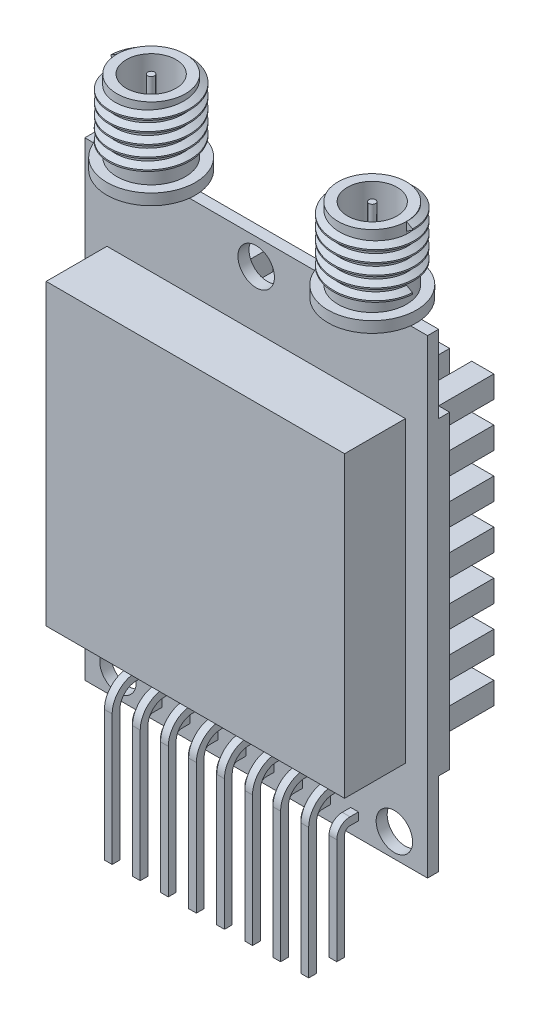
from build123d import *

# Parameters (mm, degrees)
SKETCH_1_W             = 31
SKETCH_1_H             = 42.5
EXTRUDE_1_DEPTH        = 1
SKETCH_2_W             = 27
SKETCH_2_H             = 27
EXTRUDE_2_DEPTH        = 5.5
SKETCH_3_R             = 4
EXTRUDE_3_DEPTH        = 1
SKETCH_4_R             = 3.1
EXTRUDE_4_DEPTH        = 6.5
SKETCH_6_R             = 2.25
CUT_EXTRUDE_1_DEPTH    = 5
SKETCH_7_R             = 0.3
EXTRUDE_5_DEPTH        = 5
THREAD_1_PITCH         = 1
THREAD_1_HEIGHT        = 5
THREAD_1_RADIUS        = 3.1
THREAD_1_START_ANGLE   = -90
EXTRUDE_START          = -6.25
EXTRUDE_6_DEPTH        = 0.7
EXTRUDE_6_2_DEPTH      = 0.7
PATTERN_LINEAR_1_COUNT = 8
PATTERN_LINEAR_1_PITCH = 2.54
SKETCH_9_R             = 1.65
CUT_EXTRUDE_2_DEPTH    = 60.086800641
SKETCH_10_W            = 31
SKETCH_10_H            = 28
EXTRUDE_7_DEPTH        = 6
SKETCH_11_W            = 5
SKETCH_11_H            = 2
CUT_EXTRUDE_3_DEPTH    = 60.188259055
CUT_EXTRUDE_4_REACH    = 53.415
SKETCH_12_W            = 2
SKETCH_12_H            = 5


with BuildPart() as part:
    # Эскиз1 → Бобышка-Вытянуть1 (new body)
    with BuildSketch(Plane.XY):
        with Locations((15.5, 21.25)):
            Rectangle(SKETCH_1_W, SKETCH_1_H)
    extrude(amount=EXTRUDE_1_DEPTH)

    # Sketch 2 → Бобышка-Вытянуть2 (add)
    with BuildSketch(Plane.XY.offset(1)):
        with Locations((15.5, 21.5)):
            Rectangle(SKETCH_2_W, SKETCH_2_H)
    extrude(amount=EXTRUDE_2_DEPTH)

    # Эскиз3 → Бобышка-Вытянуть3 (add)
    with BuildSketch(Plane(origin=(0, 42.5, 0), x_dir=(1, 0, 0), z_dir=(0, 1, 0))):
        with Locations(Location((5.5, -0.5, 0), (0, 0, 7.180755781))):
            Circle(SKETCH_3_R)
    extrude_3 = extrude(amount=EXTRUDE_3_DEPTH)

    # Эскиз4 → Бобышка-Вытянуть4 (add)
    with BuildSketch(Plane(origin=(0, 43.5, 0), x_dir=(1, 0, 0), z_dir=(0, 1, 0))):
        with Locations(Location((5.5, -0.5, 0), (0, 0, 90))):
            Circle(SKETCH_4_R)
    extrude_4 = extrude(amount=EXTRUDE_4_DEPTH)

    # Эскиз6 → Вырез-Вытянуть1 (cut)
    with BuildSketch(Plane(origin=(0, 50, 0), x_dir=(1, 0, 0), z_dir=(0, 1, 0))):
        with Locations(Location((5.5, -0.5, 0), (0, 0, 270))):
            Circle(SKETCH_6_R)
    cut_extrude_1 = extrude(amount=-CUT_EXTRUDE_1_DEPTH, mode=Mode.SUBTRACT)

    # Эскиз7 → Бобышка-Вытянуть5 (add)
    with BuildSketch(Plane(origin=(0, 45, 0), x_dir=(1, 0, 0), z_dir=(0, 1, 0))):
        with Locations(Location((5.5, -0.5, 0), (0, 0, 270))):
            Circle(SKETCH_7_R)
    extrude_5 = extrude(amount=EXTRUDE_5_DEPTH)

    # Резьба1: sweep along a helix
    with BuildLine() as thread_1_path:
        add(Helix(THREAD_1_PITCH, THREAD_1_HEIGHT, THREAD_1_RADIUS, center=(5.5, 50, 0.5), direction=(0, -1, 0), mode=Mode.PRIVATE).rotate(Axis((5.5, 50, 0.5), (0, -1, 0)), THREAD_1_START_ANGLE))
    # Sketch 2 2 → Резьба1 (sweep)
    with BuildSketch(Plane(origin=(2.4, 50, 0.5), x_dir=(-1, 0, 0), z_dir=(0, 0, 1))):
        Polygon((0, 0), (0.541265875, 0.312499999), (0.541265875, 0.437499999), (0, 0.749999997), align=None)
    thread_1 = sweep(path=thread_1_path.line, is_frenet=True)

    # Зеркальное отражение1: Бобышка-Вытянуть3, Бобышка-Вытянуть4, Вырез-Вытянуть1, Бобышка-Вытянуть5, Резьба1 across plane
    add(extrude_3.mirror(Plane(origin=(15.5, 0, 0), x_dir=(0, 0, 1), z_dir=(1, 0, 0))))
    add(extrude_4.mirror(Plane(origin=(15.5, 0, 0), x_dir=(0, 0, 1), z_dir=(1, 0, 0))))
    add(cut_extrude_1.mirror(Plane(origin=(15.5, 0, 0), x_dir=(0, 0, 1), z_dir=(1, 0, 0))), mode=Mode.SUBTRACT)
    add(extrude_5.mirror(Plane(origin=(15.5, 0, 0), x_dir=(0, 0, 1), z_dir=(1, 0, 0))))
    add(thread_1.mirror(Plane(origin=(15.5, 0, 0), x_dir=(0, 0, 1), z_dir=(1, 0, 0))))

    # Эскиз9 → Вырез-Вытянуть2 (cut, through all)
    with BuildSketch(Plane.XY.offset(1)):
        with Locations((15.5, 40.15)):
            Circle(SKETCH_9_R)
        with Locations((28, 2.15)):
            Circle(SKETCH_9_R)
        with Locations((3, 2.15)):
            Circle(SKETCH_9_R)
    extrude(amount=-CUT_EXTRUDE_2_DEPTH, mode=Mode.SUBTRACT)

    # Эскиз10 → Бобышка-Вытянуть7 (add)
    with BuildSketch(Plane(origin=(0, 0, 0), x_dir=(-1, 0, 0), z_dir=(0, 0, -1))):
        with Locations((-15.5, 21.5)):
            Rectangle(SKETCH_10_W, SKETCH_10_H)
    extrude(amount=EXTRUDE_7_DEPTH)

    # Эскиз11 → Вырез-Вытянуть3 (cut, through all)
    with BuildSketch(Plane.ZY):
        with Locations((-3.5, 32.5)):
            Rectangle(SKETCH_11_W, SKETCH_11_H)
        with Locations((-3.5, 28.5)):
            Rectangle(SKETCH_11_W, SKETCH_11_H)
        with Locations((-3.5, 24.5)):
            Rectangle(SKETCH_11_W, SKETCH_11_H)
        with Locations((-3.5, 20.5)):
            Rectangle(SKETCH_11_W, SKETCH_11_H)
        with Locations((-3.5, 16.5)):
            Rectangle(SKETCH_11_W, SKETCH_11_H)
        with Locations((-3.5, 12.5)):
            Rectangle(SKETCH_11_W, SKETCH_11_H)
        with Locations((-3.5, 8.5)):
            Rectangle(SKETCH_11_W, SKETCH_11_H)
    extrude(amount=-CUT_EXTRUDE_3_DEPTH, mode=Mode.SUBTRACT)

    # Вырез-Вытянуть4: up to this face of the body (flat: up to its plane)
    cut_extrude_4_end = Plane(part.part.faces().sort_by_distance((15.5, 35.5, -3))[0])
    # Эскиз12 → Вырез-Вытянуть4 (cut, up to the picked face)
    with BuildSketch(Plane.XZ.offset(-9.5), mode=Mode.PRIVATE) as cut_extrude_4_sk1:
        with Locations((3, -3.5)):
            Rectangle(SKETCH_12_W, SKETCH_12_H)
    cut_extrude_4_tool1 = split(extrude(cut_extrude_4_sk1.sketch, amount=-CUT_EXTRUDE_4_REACH, mode=Mode.PRIVATE), bisect_by=cut_extrude_4_end, keep=Keep.BOTH, mode=Mode.PRIVATE)
    # Эскиз12 → Вырез-Вытянуть4 (cut, up to the picked face)
    with BuildSketch(Plane.XZ.offset(-9.5), mode=Mode.PRIVATE) as cut_extrude_4_sk2:
        with Locations((7, -3.5)):
            Rectangle(SKETCH_12_W, SKETCH_12_H)
    cut_extrude_4_tool2 = split(extrude(cut_extrude_4_sk2.sketch, amount=-CUT_EXTRUDE_4_REACH, mode=Mode.PRIVATE), bisect_by=cut_extrude_4_end, keep=Keep.BOTH, mode=Mode.PRIVATE)
    # Эскиз12 → Вырез-Вытянуть4 (cut, up to the picked face)
    with BuildSketch(Plane.XZ.offset(-9.5), mode=Mode.PRIVATE) as cut_extrude_4_sk3:
        with Locations((11, -3.5)):
            Rectangle(SKETCH_12_W, SKETCH_12_H)
    cut_extrude_4_tool3 = split(extrude(cut_extrude_4_sk3.sketch, amount=-CUT_EXTRUDE_4_REACH, mode=Mode.PRIVATE), bisect_by=cut_extrude_4_end, keep=Keep.BOTH, mode=Mode.PRIVATE)
    # Эскиз12 → Вырез-Вытянуть4 (cut, up to the picked face)
    with BuildSketch(Plane.XZ.offset(-9.5), mode=Mode.PRIVATE) as cut_extrude_4_sk4:
        with Locations((15, -3.5)):
            Rectangle(SKETCH_12_W, SKETCH_12_H)
    cut_extrude_4_tool4 = split(extrude(cut_extrude_4_sk4.sketch, amount=-CUT_EXTRUDE_4_REACH, mode=Mode.PRIVATE), bisect_by=cut_extrude_4_end, keep=Keep.BOTH, mode=Mode.PRIVATE)
    # Эскиз12 → Вырез-Вытянуть4 (cut, up to the picked face)
    with BuildSketch(Plane.XZ.offset(-9.5), mode=Mode.PRIVATE) as cut_extrude_4_sk5:
        with Locations((19, -3.5)):
            Rectangle(SKETCH_12_W, SKETCH_12_H)
    cut_extrude_4_tool5 = split(extrude(cut_extrude_4_sk5.sketch, amount=-CUT_EXTRUDE_4_REACH, mode=Mode.PRIVATE), bisect_by=cut_extrude_4_end, keep=Keep.BOTH, mode=Mode.PRIVATE)
    # Эскиз12 → Вырез-Вытянуть4 (cut, up to the picked face)
    with BuildSketch(Plane.XZ.offset(-9.5), mode=Mode.PRIVATE) as cut_extrude_4_sk6:
        with Locations((23, -3.5)):
            Rectangle(SKETCH_12_W, SKETCH_12_H)
    cut_extrude_4_tool6 = split(extrude(cut_extrude_4_sk6.sketch, amount=-CUT_EXTRUDE_4_REACH, mode=Mode.PRIVATE), bisect_by=cut_extrude_4_end, keep=Keep.BOTH, mode=Mode.PRIVATE)
    # Эскиз12 → Вырез-Вытянуть4 (cut, up to the picked face)
    with BuildSketch(Plane.XZ.offset(-9.5), mode=Mode.PRIVATE) as cut_extrude_4_sk7:
        with Locations((27, -3.5)):
            Rectangle(SKETCH_12_W, SKETCH_12_H)
    cut_extrude_4_tool7 = split(extrude(cut_extrude_4_sk7.sketch, amount=-CUT_EXTRUDE_4_REACH, mode=Mode.PRIVATE), bisect_by=cut_extrude_4_end, keep=Keep.BOTH, mode=Mode.PRIVATE)
    # Эскиз12 → Вырез-Вытянуть4 (cut, up to the picked face)
    with BuildSketch(Plane.XZ.offset(-9.5), mode=Mode.PRIVATE) as cut_extrude_4_sk8:
        with Locations((31, -3.5)):
            Rectangle(SKETCH_12_W, SKETCH_12_H)
    cut_extrude_4_tool8 = split(extrude(cut_extrude_4_sk8.sketch, amount=-CUT_EXTRUDE_4_REACH, mode=Mode.PRIVATE), bisect_by=cut_extrude_4_end, keep=Keep.BOTH, mode=Mode.PRIVATE)
    add(cut_extrude_4_tool1.solids().sort_by(Axis((3, 9.5, -3.5), (0, 1, 0)))[0], mode=Mode.SUBTRACT)
    add(cut_extrude_4_tool2.solids().sort_by(Axis((7, 9.5, -3.5), (0, 1, 0)))[0], mode=Mode.SUBTRACT)
    add(cut_extrude_4_tool3.solids().sort_by(Axis((11, 9.5, -3.5), (0, 1, 0)))[0], mode=Mode.SUBTRACT)
    add(cut_extrude_4_tool4.solids().sort_by(Axis((15, 9.5, -3.5), (0, 1, 0)))[0], mode=Mode.SUBTRACT)
    add(cut_extrude_4_tool5.solids().sort_by(Axis((19, 9.5, -3.5), (0, 1, 0)))[0], mode=Mode.SUBTRACT)
    add(cut_extrude_4_tool6.solids().sort_by(Axis((23, 9.5, -3.5), (0, 1, 0)))[0], mode=Mode.SUBTRACT)
    add(cut_extrude_4_tool7.solids().sort_by(Axis((27, 9.5, -3.5), (0, 1, 0)))[0], mode=Mode.SUBTRACT)
    add(cut_extrude_4_tool8.solids().sort_by(Axis((31, 9.5, -3.5), (0, 1, 0)))[0], mode=Mode.SUBTRACT)


with BuildPart() as body_2:
    # Эскиз8 → Бобышка-Вытянуть6 (new body)
    with BuildSketch(Plane(origin=(31, 0, 0), x_dir=(0, 0, -1), z_dir=(1, 0, 0)).offset(EXTRUDE_START)):
        with BuildLine():
            Line((-1, 5.3), (-3.3, 5.3))
            ThreePointArc((-3.3, 5.3), (-4.855634919, 4.655634919), (-5.5, 3.1))
            Line((-5.5, 3.1), (-5.5, -8.7))
            Line((-5.5, -8.7), (-4.8, -8.7))
            Line((-4.8, -8.7), (-4.8, 3.1))
            ThreePointArc((-4.8, 3.1), (-4.360660172, 4.160660172), (-3.3, 4.6))
            Line((-3.3, 4.6), (-1, 4.6))
            Line((-1, 4.6), (-1, 5.3))
        make_face()
    extrude_6 = extrude(amount=-EXTRUDE_6_DEPTH)


with BuildPart() as body_3:
    # Эскиз8 → Extrude 6 2 (new body)
    with BuildSketch(Plane(origin=(31, 0, 0), x_dir=(0, 0, -1), z_dir=(1, 0, 0)).offset(EXTRUDE_START)):
        with BuildLine():
            Line((-2.96, -8.7), (-2.26, -8.7))
            Line((-2.26, -8.7), (-2.26, 0.86))
            ThreePointArc((-2.26, 0.86), (-2.113553391, 1.213553391), (-1.76, 1.36))
            Line((-1.76, 1.36), (-1, 1.36))
            Line((-1, 1.36), (-1, 2.06))
            Line((-1, 2.06), (-1.76, 2.06))
            ThreePointArc((-1.76, 2.06), (-2.608528137, 1.708528137), (-2.96, 0.86))
            Line((-2.96, 0.86), (-2.96, -8.7))
        make_face()
    extrude_6_2 = extrude(amount=-EXTRUDE_6_2_DEPTH)


with BuildPart() as pattern_linear_1_1:
    # Линейный массив1: Бобышка-Вытянуть6, Extrude 6 2 ×8
    with Locations(*[(-i * PATTERN_LINEAR_1_PITCH, 0, 0) for i in range(1, PATTERN_LINEAR_1_COUNT)]):
        add(extrude_6)
        add(extrude_6_2)


solid = Compound([part.part, body_2.part, body_3.part, pattern_linear_1_1.part])
